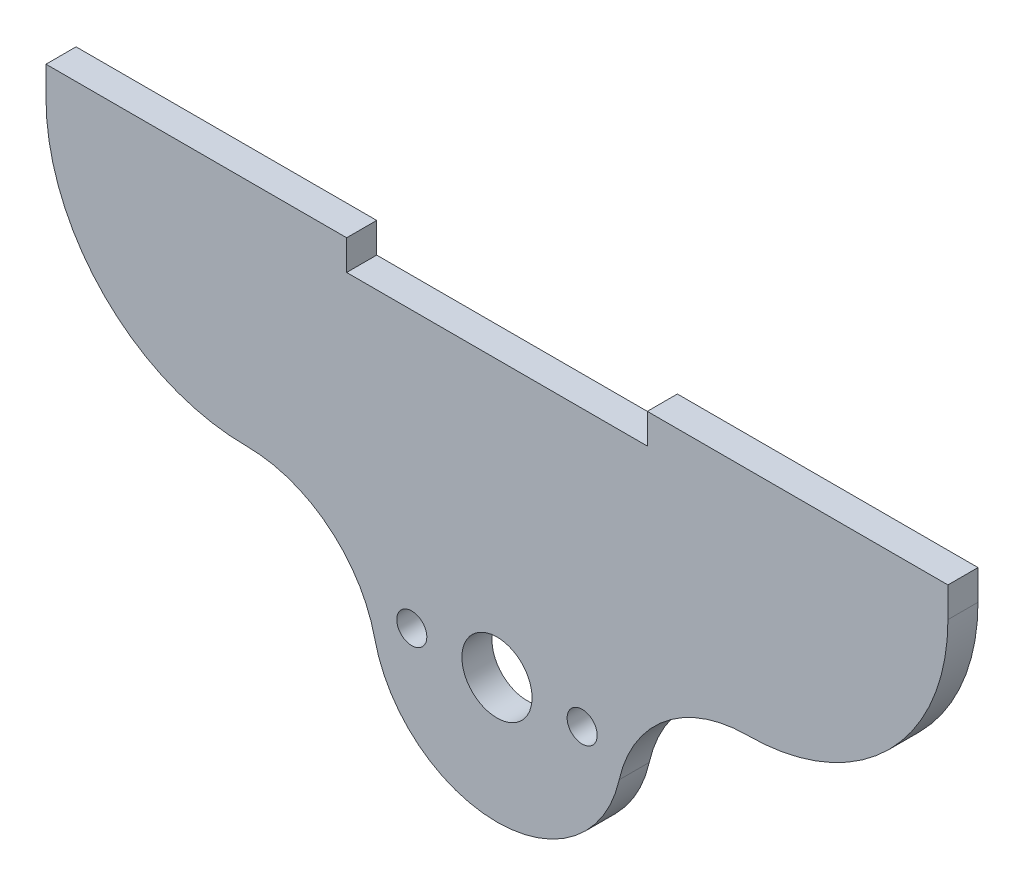
from build123d import *

# Parameters (mm, degrees)
SKETCH1_R           = 1.5
SKETCH1_R_2         = 3.5
BOSS_EXTRUDE1_DEPTH = 3


with BuildPart() as part:
    # Sketch1 → Boss-Extrude1 (new body)
    with BuildSketch(Plane.XY):
        with BuildLine():
            Line((-15, 27.5), (15, 27.5))
            Line((15, 27.5), (15, 30.5))
            Line((15, 30.5), (45, 30.5))
            Line((45, 30.5), (45, 27.5))
            ThreePointArc((45, 27.5), (39.142135624, 13.357864376), (25, 7.5))
            ThreePointArc((25, 7.5), (16.800877501, 4.623903124), (12.195121951, -2.743902439))
            ThreePointArc((12.195121951, -2.743902439), (0, -12.5), (-12.195121951, -2.743902439))
            ThreePointArc((-12.195121951, -2.743902439), (-16.800877501, 4.623903124), (-25, 7.5))
            ThreePointArc((-25, 7.5), (-39.142135624, 13.357864376), (-45, 27.5))
            Line((-45, 27.5), (-45, 30.5))
            Line((-45, 30.5), (-15, 30.5))
            Line((-15, 30.5), (-15, 27.5))
        make_face()
        with Locations((-8.5, 0)):
            Circle(SKETCH1_R, mode=Mode.SUBTRACT)
        with Locations((8.5, 0)):
            Circle(SKETCH1_R, mode=Mode.SUBTRACT)
        Circle(SKETCH1_R_2, mode=Mode.SUBTRACT)
    extrude(amount=BOSS_EXTRUDE1_DEPTH)


solid = part.part
